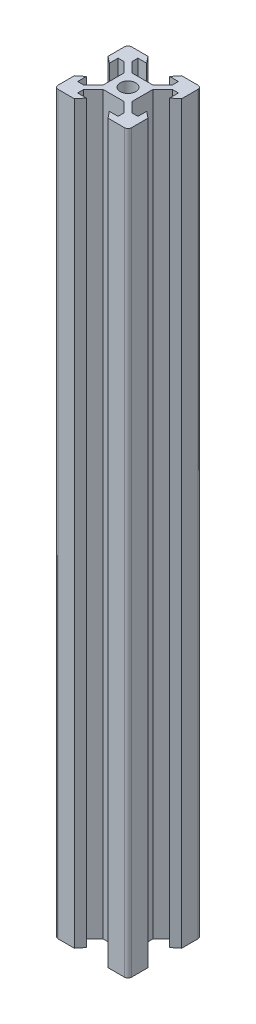
from build123d import *

# Parameters (mm, degrees)
SKETCH1_R           = 2.1
BOSS_EXTRUDE1_DEPTH = 200


with BuildPart() as part:
    # Sketch1 → Boss-Extrude1 (new body)
    with BuildSketch(Plane(origin=(0, 0, 0), x_dir=(1, 0, 0), z_dir=(0, 1, 0))):
        with BuildLine():
            Line((-5.5, 8.2), (-3.125, 8.2))
            Line((-3.125, 8.2), (-4.58, 10))
            Line((-4.58, 10), (-9, 10))
            ThreePointArc((-9, 10), (-9.707106781, 9.707106781), (-10, 9))
            Line((-10, 9), (-10, 4.58))
            Line((-10, 4.58), (-8.2, 3.125))
            Line((-8.2, 3.125), (-8.2, 5.5))
            Line((-8.2, 5.5), (-6.56, 5.5))
            Line((-6.56, 5.5), (-3.9, 2.84))
            Line((-3.9, 2.84), (-3.9, -2.84))
            Line((-3.9, -2.84), (-6.56, -5.5))
            Line((-6.56, -5.5), (-8.2, -5.5))
            Line((-8.2, -5.5), (-8.2, -3.125))
            Line((-8.2, -3.125), (-10, -4.58))
            Line((-10, -4.58), (-10, -9))
            ThreePointArc((-10, -9), (-9.707106781, -9.707106781), (-9, -10))
            Line((-9, -10), (-4.58, -10))
            Line((-4.58, -10), (-3.125, -8.2))
            Line((-3.125, -8.2), (-5.5, -8.2))
            Line((-5.5, -8.2), (-5.5, -6.56))
            Line((-5.5, -6.56), (-2.84, -3.9))
            Line((-2.84, -3.9), (2.84, -3.9))
            Line((2.84, -3.9), (5.5, -6.56))
            Line((5.5, -6.56), (5.5, -8.2))
            Line((5.5, -8.2), (3.125, -8.2))
            Line((3.125, -8.2), (4.58, -10))
            Line((4.58, -10), (9, -10))
            ThreePointArc((9, -10), (9.707106781, -9.707106781), (10, -9))
            Line((10, -9), (10, -4.58))
            Line((10, -4.58), (8.2, -3.125))
            Line((8.2, -3.125), (8.2, -5.5))
            Line((8.2, -5.5), (6.56, -5.5))
            Line((6.56, -5.5), (3.9, -2.84))
            Line((3.9, -2.84), (3.9, 2.84))
            Line((3.9, 2.84), (6.56, 5.5))
            Line((6.56, 5.5), (8.2, 5.5))
            Line((8.2, 5.5), (8.2, 3.125))
            Line((8.2, 3.125), (10, 4.58))
            Line((10, 4.58), (10, 9))
            ThreePointArc((10, 9), (9.707106781, 9.707106781), (9, 10))
            Line((9, 10), (4.58, 10))
            Line((4.58, 10), (3.125, 8.2))
            Line((3.125, 8.2), (5.5, 8.2))
            Line((5.5, 8.2), (5.5, 6.56))
            Line((5.5, 6.56), (2.84, 3.9))
            Line((2.84, 3.9), (-2.84, 3.9))
            Line((-2.84, 3.9), (-5.5, 6.56))
            Line((-5.5, 6.56), (-5.5, 8.2))
        make_face()
        Circle(SKETCH1_R, mode=Mode.SUBTRACT)
    extrude(amount=BOSS_EXTRUDE1_DEPTH)


solid = part.part
